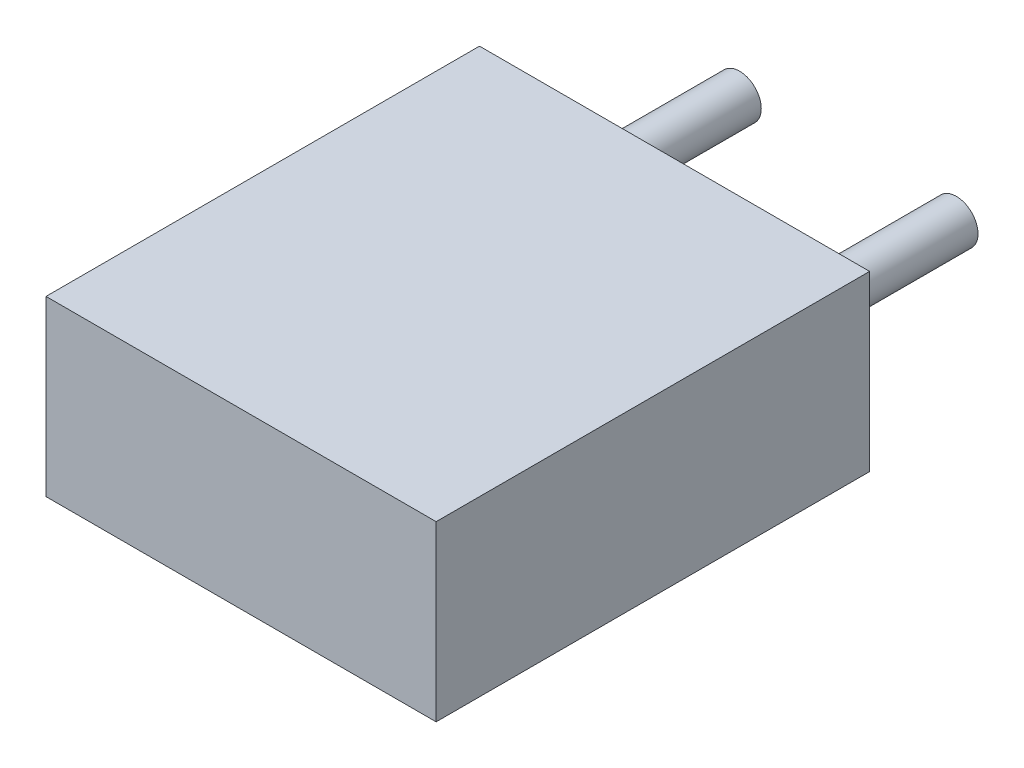
from build123d import *

# Parameters (mm, degrees)
SKETCH1_W               = 4.5
SKETCH1_H               = 2
COMPONENT_OUTLINE_DEPTH = 5
SKETCH2_R               = 0.25
EXTRUDE_1_DEPTH         = 2
SKETCH3_R               = 0.25
EXTRUDE_2_DEPTH         = 2


with BuildPart() as part:
    # Sketch1 → Component_Outline (new body)
    with BuildSketch(Plane.XY):
        with Locations((1.25, 0)):
            Rectangle(SKETCH1_W, SKETCH1_H)
    extrude(amount=COMPONENT_OUTLINE_DEPTH)


with BuildPart() as body_2:
    # Sketch2 → Extrude 1 (new body)
    with BuildSketch(Plane.XY):
        Circle(SKETCH2_R)
    extrude(amount=-EXTRUDE_1_DEPTH)


with BuildPart() as body_3:
    # Sketch3 → Extrude 2 (new body)
    with BuildSketch(Plane.XY):
        with Locations((2.5, 0)):
            Circle(SKETCH3_R)
    extrude(amount=-EXTRUDE_2_DEPTH)


solid = Compound([part.part, body_2.part, body_3.part])
